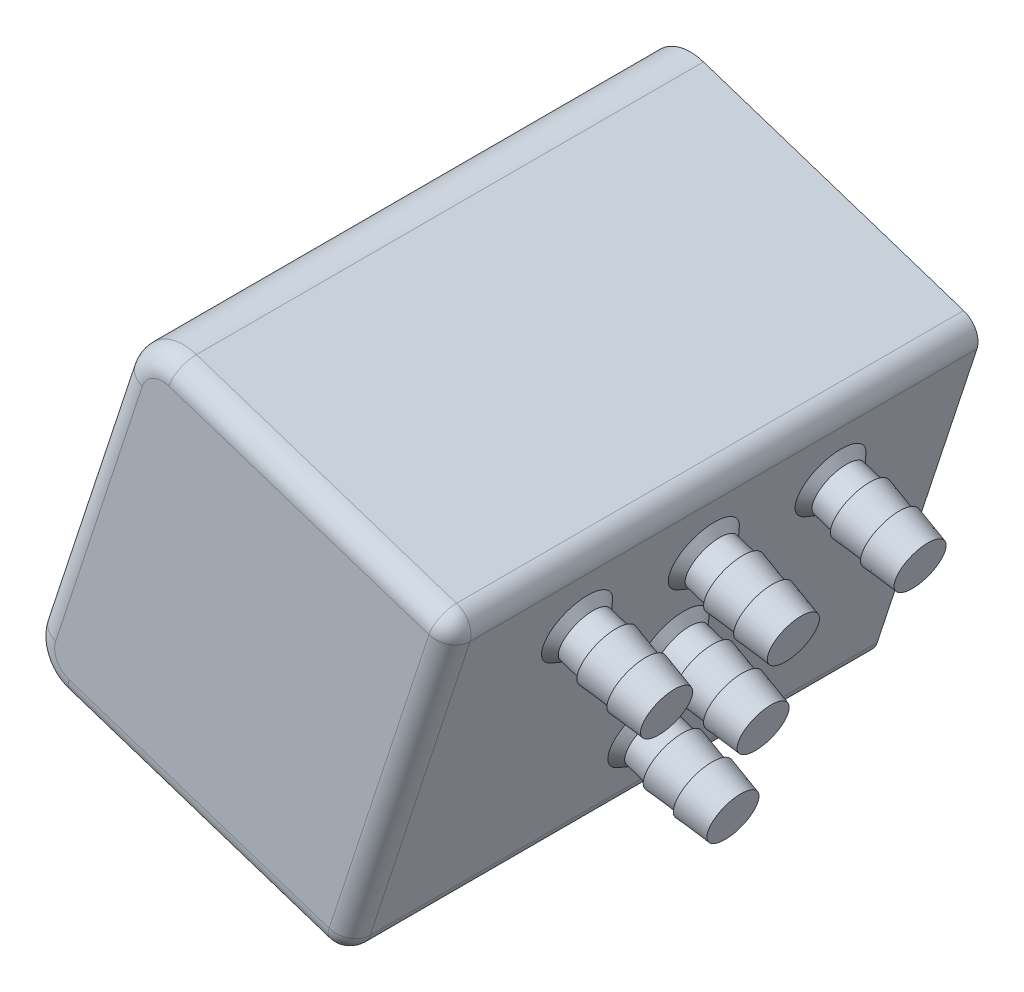
from build123d import *

# Parameters (mm, degrees)
BOSS_EXTRUDE1_DEPTH              = 79.642695409
FILLET1_R                        = 6.35
FILLET2_R                        = 3.175
SKETCH7_R                        = 4.261789822
CUT_EXTRUDE1_DEPTH               = 9.453613484
CHAMFER1_SIZE                    = 1.27
CHAMFER1_OF_SKETCH_PATTERN2_SIZE = 1.27
HOLE1_AT_2_COUNT                 = 2
HOLE1_AT_2_PITCH                 = 35.575698059
HOLE1_AT_3_COUNT                 = 2
HOLE1_AT_3_PITCH                 = 28.575
HOLE1_AT_4_COUNT                 = 2
HOLE1_AT_4_PITCH                 = 45.630701478
F_8_CLEARANCE_HOLE1_D            = 4.9149
F_8_CLEARANCE_HOLE1_DEPTH        = 12.7
F_8_CLEARANCE_HOLE1_TIP          = 1.476584928


with BuildPart() as part:
    # Sketch1 → Boss-Extrude1 (new body)
    with BuildSketch(Plane.XY):
        Polygon((290.280862854, 502.979981998), (307.307307279, 554.884385267), (355.576597736, 539.050383917), (338.550153311, 487.145980648), align=None)
    extrude(amount=BOSS_EXTRUDE1_DEPTH)

    # Fillet1
    fillet1_edges = [part.edges().sort_by_distance(p)[0] for p in [
        (307.307307279, 554.884385267, 39.821347704),
        (290.280862854, 502.979981998, 39.821347704),
    ]]
    fillet(fillet1_edges, radius=FILLET1_R)

    # Fillet2
    fillet2_edges = [part.edges().sort_by_distance(p)[0] for p in [
        (338.550153311, 487.145980648, 39.821347704),
        (298.794085066, 528.932183632, 79.642695409),
        (355.576597736, 539.050383917, 39.821347704),
        (317.432338736, 494.073356239, 79.642695409),
        (292.627790288, 504.167491527, 79.642695409),
        (308.494816808, 552.537457832, 79.642695409),
        (347.063375524, 513.098182283, 79.642695409),
        (334.458783161, 545.977759508, 79.642695409),
    ]]
    fillet(fillet2_edges, radius=FILLET2_R)

    # Sketch6 → Revolve1 (revolve)
    with BuildSketch(Plane.XY.offset(38.233847704), mode=Mode.PRIVATE) as revolve1_sk:
        Polygon((342.508653649, 499.213303263), (365.002143002, 491.834658634), (366.142191099, 495.310047547), (361.824191099, 497.311751702), (361.665851086, 496.829058798), (357.347851086, 498.830762953), (357.189511072, 498.348070049), (352.871511072, 500.349774204), (352.713171059, 499.8670813), (348.395171059, 501.868785456), (348.236831045, 501.386092551), (343.708665123, 502.87148802), align=None)
    revolve1 = revolve(revolve1_sk.sketch.rotate(Axis((342.508653649, 499.213303263, 38.233847704), (0.950182883020466, -0.31169293995038694, 0)), 180), axis=Axis((342.508653649, 499.213303263, 38.233847704), (0.950182883020466, -0.31169293995038694, 0)))

    # Sketch7 → Cut-Extrude1 (cut)
    with BuildSketch(Plane(origin=(183.876918982, -60.31800666, 0), x_dir=(0, 0, -1), z_dir=(0.9501828830204668, -0.31169293995038483, 0))):
        with Locations((-38.233847704, 581.101464951)):
            Circle(SKETCH7_R)
    cut_extrude1 = extrude(amount=-CUT_EXTRUDE1_DEPTH, mode=Mode.SUBTRACT)

    # Chamfer1
    chamfer1_edges = [part.edges().sort_by_distance(p)[0] for p in [
        (343.708665123, 502.87148802, 38.233847704),
    ]]
    chamfer(chamfer1_edges, length=CHAMFER1_SIZE)

    # Sketch-Pattern2: Revolve1, Cut-Extrude1 at 4 more places
    with Locations((9.109444, 27.769758, 0), (4.554722, 13.884879, 0), (9.109444, 27.769758, 19.116924), (9.109444, 27.769758, -19.116924)):
        add(revolve1)
        add(cut_extrude1, mode=Mode.SUBTRACT)

    # Chamfer1 of Sketch-Pattern2
    chamfer1_of_sketch_pattern2_edges = [part.edges().sort_by_distance(p)[0] for p in [
        (352.818109123, 530.64124602, 38.233847704),
        (348.263387123, 516.75636702, 38.233847704),
        (352.818109123, 530.64124602, 57.350771704),
        (352.818109123, 530.64124602, 19.116923704),
    ]]
    chamfer(chamfer1_of_sketch_pattern2_edges, length=CHAMFER1_OF_SKETCH_PATTERN2_SIZE)

    # Sketch9 → Hole1 (revolve, cut)
    with BuildSketch(Plane(origin=(332.468536604, 499.165347862, 0), x_dir=(0, 1, 0), z_dir=(1, 0, 0))):
        Polygon((0, 0), (0, 4.699), (2.8702, 4.699), (2.9972, 0), align=None)
    hole1 = revolve(axis=Axis((332.468536604, 499.165347862, 110), (0, 0, -1)), mode=Mode.SUBTRACT)

    # Hole1 at 2: Hole1 ×2
    with Locations(*[Vector(0.3116929399504022, 0.950182883020461, 0) * (i * HOLE1_AT_2_PITCH) for i in range(1, HOLE1_AT_2_COUNT)]):
        add(hole1, mode=Mode.SUBTRACT)

    # Hole1 at 3: Hole1 ×2
    with Locations(*[Vector(-0.9501828830204608, 0.3116929399504024, 0) * (i * HOLE1_AT_3_PITCH) for i in range(1, HOLE1_AT_3_COUNT)]):
        add(hole1, mode=Mode.SUBTRACT)

    # Hole1 at 4: Hole1 ×2
    with Locations(*[Vector(-0.3520169851244571, 0.9359936122559213, 0) * (i * HOLE1_AT_4_PITCH) for i in range(1, HOLE1_AT_4_COUNT)]):
        add(hole1, mode=Mode.SUBTRACT)

    # #8 Clearance Hole1
    with Locations(Plane(origin=(0, 0, 0), x_dir=(-1, 0, 0), z_dir=(0, 0, -1))):
        with Locations((-332.468536604, 499.165347862), (-343.557230523, 532.968767209), (-316.40575464, 541.875392969), (-305.317060721, 508.071973621)):
            Hole(F_8_CLEARANCE_HOLE1_D / 2, depth=F_8_CLEARANCE_HOLE1_DEPTH)
            with Locations((0, 0, -(F_8_CLEARANCE_HOLE1_DEPTH + F_8_CLEARANCE_HOLE1_TIP / 2))):  # 118° drill point
                Cone(0, F_8_CLEARANCE_HOLE1_D / 2, F_8_CLEARANCE_HOLE1_TIP, mode=Mode.SUBTRACT)


solid = part.part
